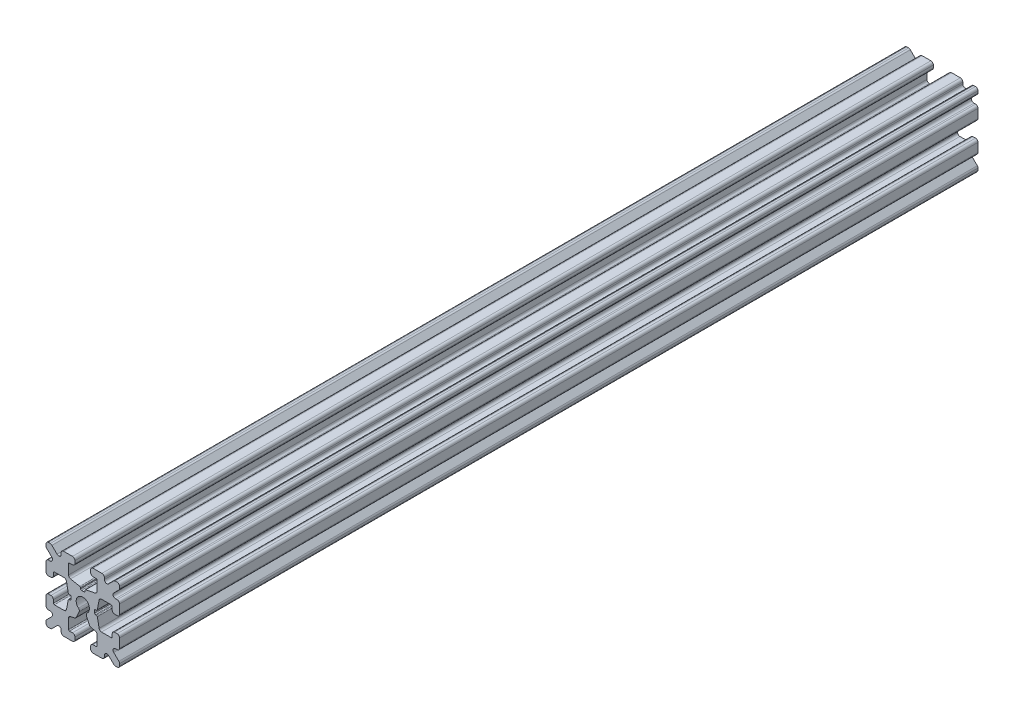
from build123d import *

# Parameters (mm, degrees)
SKETCH1_W           = 15
SKETCH1_H           = 15
SKETCH1_R           = 1.35
BOSS_EXTRUDE1_DEPTH = 87.5
FILLET1_R           = 0.5
CUT_EXTRUDE1_DEPTH  = 176
CUT_EXTRUDE3_DEPTH  = 176
FILLET3_R           = 0.5
FILLET4_R           = 0.5
FILLET5_R           = 3
FILLET6_R           = 0.2
CUT_EXTRUDE4_DEPTH  = 176
FILLET8_R           = 0.5
SKETCH6_W           = 6.249171159
SKETCH6_H           = 0.889
SKETCH6_W_2         = 0.889
SKETCH6_H_2         = 6.249171159
CUT_EXTRUDE5_DEPTH  = 176
CUT_EXTRUDE6_DEPTH  = 176
FILLET9_R           = 0.5
FILLET10_R          = 0.2


with BuildPart() as part:
    # Sketch1 → Boss-Extrude1 (new body, symmetric)
    with BuildSketch(Plane.XY):
        Rectangle(SKETCH1_W, SKETCH1_H)
        Circle(SKETCH1_R, mode=Mode.SUBTRACT)
    extrude(amount=BOSS_EXTRUDE1_DEPTH, both=True)

    # Fillet1
    fillet1_edges = [part.edges().sort_by_distance(p)[0] for p in [
        (7.5, -7.5, 0),
        (-7.5, -7.5, 0),
        (-7.5, 7.5, 0),
        (7.5, 7.5, 0),
    ]]
    fillet(fillet1_edges, radius=FILLET1_R)

    # Sketch2 → Cut-Extrude1 (cut, through all)
    with BuildSketch(Plane.XY.offset(87.5)):
        Polygon((-7.5, 1.6), (-6, 1.6), (-6, 2.9), (-3.4, 2.9), (-3.4, -2.9), (-6, -2.9), (-6, -1.6), (-7.5, -1.6), align=None)
        Polygon((2.9, 6), (1.6, 6), (1.6, 7.5), (-1.6, 7.5), (-1.6, 6), (-2.9, 6), (-2.9, 3.4), (2.9, 3.4), align=None)
        Polygon((-1.6, -7.5), (-1.6, -6), (-2.9, -6), (-2.9, -3.4), (2.9, -3.4), (2.9, -6), (1.6, -6), (1.6, -7.5), align=None)
        Polygon((6, -2.9), (6, -1.6), (7.5, -1.6), (7.5, 1.6), (6, 1.6), (6, 2.9), (3.4, 2.9), (3.4, -2.9), align=None)
    extrude(amount=-CUT_EXTRUDE1_DEPTH, mode=Mode.SUBTRACT)

    # Sketch4 → Cut-Extrude3 (cut, through all)
    with BuildSketch(Plane.XY.offset(87.5)):
        Polygon((-3.4, 2.9), (-2.85, 0), (-3.4, -2.9), align=None)
        Polygon((-2.9, 3.4), (0, 2.85), (2.9, 3.4), align=None)
        Polygon((3.4, 2.9), (2.85, 0), (3.4, -2.9), align=None)
        Polygon((-2.9, -3.4), (0, -2.85), (2.9, -3.4), align=None)
    extrude(amount=-CUT_EXTRUDE3_DEPTH, mode=Mode.SUBTRACT)

    # Fillet3
    fillet3_edges = [part.edges().sort_by_distance(p)[0] for p in [
        (1.6, -7.5, 0),
        (-1.6, -7.5, 0),
        (-1.6, -6, 0),
        (1.6, -6, 0),
        (6, 1.6, 0),
        (7.5, 1.6, 0),
        (7.5, -1.6, 0),
        (6, -1.6, 0),
        (-7.5, -1.6, 0),
        (-7.5, 1.6, 0),
        (-6, 1.6, 0),
        (-6, -1.6, 0),
        (-1.6, 6, 0),
        (-1.6, 7.5, 0),
        (1.6, 7.5, 0),
        (1.6, 6, 0),
    ]]
    fillet(fillet3_edges, radius=FILLET3_R)

    # Fillet4
    fillet4_edges = [part.edges().sort_by_distance(p)[0] for p in [
        (-2.9, -3.4, 0),
        (2.9, -3.4, 0),
        (3.4, -2.9, 0),
        (3.4, 2.9, 0),
        (-3.4, 2.9, 0),
        (-3.4, -2.9, 0),
        (2.9, 3.4, 0),
        (-2.9, 3.4, 0),
    ]]
    fillet(fillet4_edges, radius=FILLET4_R)

    # Fillet5
    fillet5_edges = [part.edges().sort_by_distance(p)[0] for p in [
        (-2.85, 0, 0),
        (0, 2.85, 0),
        (2.85, 0, 0),
        (0, -2.85, 0),
    ]]
    fillet(fillet5_edges, radius=FILLET5_R)

    # Fillet6
    fillet6_edges = [part.edges().sort_by_distance(p)[0] for p in [
        (-2.9, -6, 0),
        (2.9, -6, 0),
        (6, -2.9, 0),
        (6, 2.9, 0),
        (-6, 2.9, 0),
        (-6, -2.9, 0),
        (2.9, 6, 0),
        (-2.9, 6, 0),
    ]]
    fillet(fillet6_edges, radius=FILLET6_R)

    # Sketch5 → Cut-Extrude4 (cut, through all)
    with BuildSketch(Plane.XY.offset(87.5)):
        Polygon((-7.5, 6.439339828), (-5.460660172, 4.4), (-7.5, 4.4), align=None)
        Polygon((-6.439339828, 7.5), (-4.4, 5.460660172), (-4.4, 7.5), align=None)
        Polygon((4.4, 7.5), (6.439339828, 7.5), (4.4, 5.460660172), align=None)
        Polygon((7.5, 6.439339828), (7.5, 4.4), (5.460660172, 4.4), align=None)
        Polygon((7.5, -6.439339828), (5.460660172, -4.4), (7.5, -4.4), align=None)
        Polygon((6.439339828, -7.5), (4.4, -5.460660172), (4.4, -7.5), align=None)
        Polygon((-4.4, -7.5), (-6.439339828, -7.5), (-4.4, -5.460660172), align=None)
        Polygon((-7.5, -6.439339828), (-7.5, -4.4), (-5.460660172, -4.4), align=None)
    extrude(amount=-CUT_EXTRUDE4_DEPTH, mode=Mode.SUBTRACT)

    # Fillet8
    fillet8_edges = [part.edges().sort_by_distance(p)[0] for p in [
        (-7.5, 4.4, 0),
        (-7.5, 6.439339828, 0),
        (-5.460660172, 4.4, 0),
        (7.5, -4.4, 0),
        (7.5, -6.439339828, 0),
        (5.460660172, -4.4, 0),
        (5.460660172, 4.4, 0),
        (7.5, 6.439339828, 0),
        (7.5, 4.4, 0),
        (-4.4, 7.5, 0),
        (-4.4, 5.460660172, 0),
        (-6.439339828, 7.5, 0),
        (-5.460660172, -4.4, 0),
        (-7.5, -6.439339828, 0),
        (-7.5, -4.4, 0),
        (4.4, 5.460660172, 0),
        (4.4, 7.5, 0),
        (6.439339828, 7.5, 0),
        (6.439339828, -7.5, 0),
        (4.4, -7.5, 0),
        (4.4, -5.460660172, 0),
        (-6.439339828, -7.5, 0),
        (-4.4, -5.460660172, 0),
        (-4.4, -7.5, 0),
    ]]
    fillet(fillet8_edges, radius=FILLET8_R)

    # Sketch6 → Cut-Extrude5 (cut, through all)
    with BuildSketch(Plane.XY.offset(87.5)):
        with Locations((5.530603002, 0)):
            Rectangle(SKETCH6_W, SKETCH6_H)
        with Locations((-5.530603002, 0)):
            Rectangle(SKETCH6_W, SKETCH6_H)
        with Locations((0, 5.530603002)):
            Rectangle(SKETCH6_W_2, SKETCH6_H_2)
    extrude(amount=-CUT_EXTRUDE5_DEPTH, mode=Mode.SUBTRACT)

    # Sketch7 → Cut-Extrude6 (cut, through all)
    with BuildSketch(Plane.XY.offset(87.5)):
        Polygon((0, 0), (-2.153335353, -4.617842566), (2.153335353, -4.617842566), align=None)
    extrude(amount=-CUT_EXTRUDE6_DEPTH, mode=Mode.SUBTRACT)

    # Fillet9
    fillet9_edges = [part.edges().sort_by_distance(p)[0] for p in [
        (1.457911068, -3.126500375, 0),
        (-1.457911068, -3.126500375, 0),
        (-0.570534653, -1.223515512, 0),
        (0.570534653, -1.223515512, 0),
    ]]
    fillet(fillet9_edges, radius=FILLET9_R)

    # Fillet10
    fillet10_edges = [part.edges().sort_by_distance(p)[0] for p in [
        (-2.406017422, 0.4445, 0),
        (-2.406017422, -0.4445, 0),
        (0.4445, 2.406017422, 0),
        (-0.4445, 2.406017422, 0),
        (2.406017422, 0.4445, 0),
        (2.406017422, -0.4445, 0),
        (-2.93658978, -0.4445, 0),
        (-2.93658978, 0.4445, 0),
        (2.93658978, -0.4445, 0),
        (2.93658978, 0.4445, 0),
        (0.4445, 2.93658978, 0),
        (-0.4445, 2.93658978, 0),
    ]]
    fillet(fillet10_edges, radius=FILLET10_R)


solid = part.part
